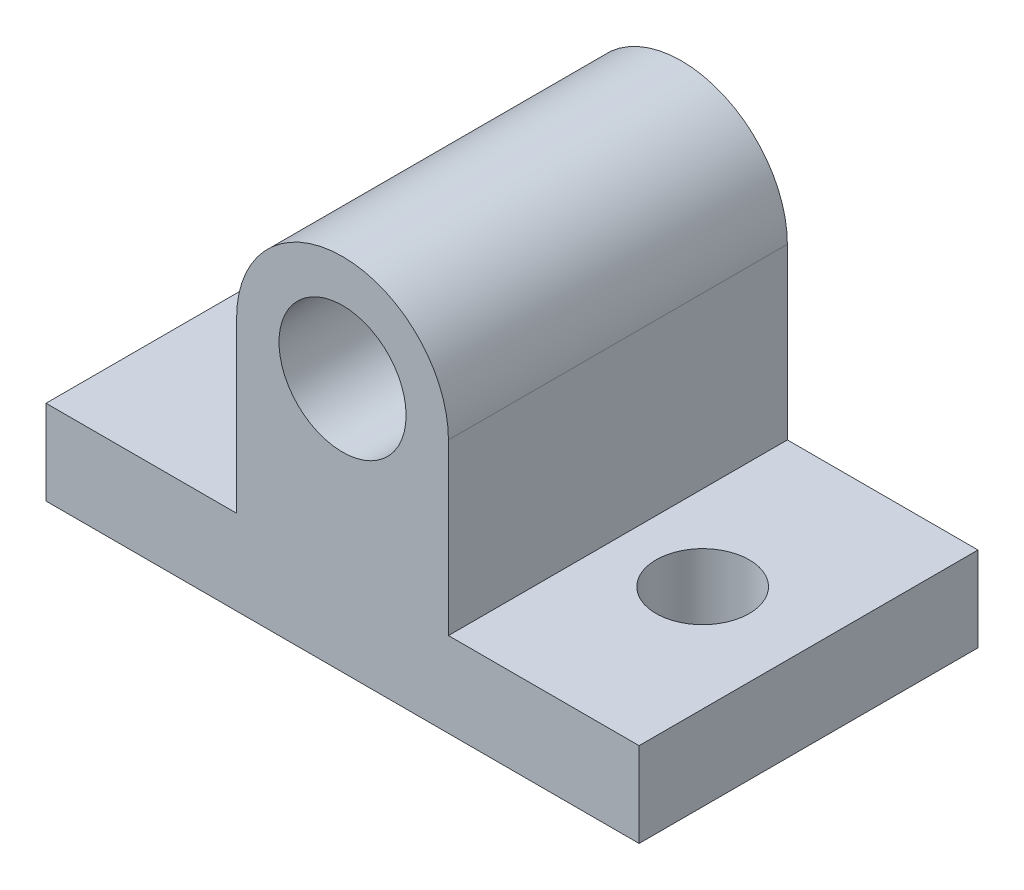
from build123d import *

# Parameters (mm, degrees)
BASE_SKETCH_W                        = 14
BASE_SKETCH_H                        = 8
BASE_EXTRUDE_DEPTH                   = 2
PROTRUSION_EXTRUDE_REACH             = 6
PROTRUSION_SKETCH_W                  = 5
PROTRUSION_SKETCH_H                  = 4
PROTRUSION_EXTRUDE_DIRECTION_2_REACH = 6
F_3_0_3_DIAMETER_HOLE1_D             = 3
F_2_2_2_2_DIAMETER_HOLE1_D           = 2.2
F_3_0_3_DIAMETER_HOLE2_D             = 3
F_3_0_3_DIAMETER_HOLE2_DEPTH         = 6
F_3_0_3_DIAMETER_HOLE2_TIP           = 0.901290929
F_5MM_CUT_SKETCH_R                   = 2.5
F_5_MM_DIAMETER_CUT_DEPTH            = 0.7


with BuildPart() as part:
    # Base Sketch → Base Extrude (new body)
    with BuildSketch(Plane(origin=(0, 0, 0), x_dir=(1, 0, 0), z_dir=(0, 1, 0))):
        Rectangle(BASE_SKETCH_W, BASE_SKETCH_H)
    extrude(amount=BASE_EXTRUDE_DEPTH)

    # Protrusion Extrude: up to this face of the body (flat: up to its plane)
    protrusion_extrude_end = Plane(part.part.faces().sort_by_distance((0, 1, 4))[0])
    # Protrusion Sketch → Protrusion Extrude (add, up to the picked face)
    with BuildSketch(Plane.XY, mode=Mode.PRIVATE) as protrusion_extrude_sk1:
        with BuildLine():
            ThreePointArc((-2.5, 6), (0, 8.5), (2.5, 6))
            Line((2.5, 6), (-2.5, 6))
        make_face()
    protrusion_extrude_tool1 = split(extrude(protrusion_extrude_sk1.sketch, amount=PROTRUSION_EXTRUDE_REACH, mode=Mode.PRIVATE), bisect_by=protrusion_extrude_end, keep=Keep.BOTH, mode=Mode.PRIVATE)
    add(protrusion_extrude_tool1.solids().sort_by_distance((0, 7.061033, 0))[0])
    # Protrusion Sketch → Protrusion Extrude (add, up to the picked face)
    with BuildSketch(Plane.XY, mode=Mode.PRIVATE) as protrusion_extrude_sk2:
        with Locations((0, 4)):
            Rectangle(PROTRUSION_SKETCH_W, PROTRUSION_SKETCH_H)
    protrusion_extrude_tool2 = split(extrude(protrusion_extrude_sk2.sketch, amount=PROTRUSION_EXTRUDE_REACH, mode=Mode.PRIVATE), bisect_by=protrusion_extrude_end, keep=Keep.BOTH, mode=Mode.PRIVATE)
    add(protrusion_extrude_tool2.solids().sort_by_distance((0, 4, 0))[0])

    # Protrusion Extrude direction 2: up to this face of the body (flat: up to its plane)
    protrusion_extrude_direction_2_end = Plane(part.part.faces().sort_by_distance((0, 1, -4))[0])
    # Protrusion Sketch → Protrusion Extrude direction 2 (add, up to the picked face)
    with BuildSketch(Plane.XY, mode=Mode.PRIVATE) as protrusion_extrude_direction_2_sk1:
        with BuildLine():
            ThreePointArc((-2.5, 6), (0, 8.5), (2.5, 6))
            Line((2.5, 6), (-2.5, 6))
        make_face()
    protrusion_extrude_direction_2_tool1 = split(extrude(protrusion_extrude_direction_2_sk1.sketch, amount=-PROTRUSION_EXTRUDE_DIRECTION_2_REACH, mode=Mode.PRIVATE), bisect_by=protrusion_extrude_direction_2_end, keep=Keep.BOTH, mode=Mode.PRIVATE)
    add(protrusion_extrude_direction_2_tool1.solids().sort_by_distance((0, 7.061033, 0))[0])
    # Protrusion Sketch → Protrusion Extrude direction 2 (add, up to the picked face)
    with BuildSketch(Plane.XY, mode=Mode.PRIVATE) as protrusion_extrude_direction_2_sk2:
        with Locations((0, 4)):
            Rectangle(PROTRUSION_SKETCH_W, PROTRUSION_SKETCH_H)
    protrusion_extrude_direction_2_tool2 = split(extrude(protrusion_extrude_direction_2_sk2.sketch, amount=-PROTRUSION_EXTRUDE_DIRECTION_2_REACH, mode=Mode.PRIVATE), bisect_by=protrusion_extrude_direction_2_end, keep=Keep.BOTH, mode=Mode.PRIVATE)
    add(protrusion_extrude_direction_2_tool2.solids().sort_by_distance((0, 4, 0))[0])

    # Ø3.0 (3) Diameter Hole1 (through all)
    with Locations(Plane.XY.offset(4)):
        with Locations((0, 6)):
            Hole(F_3_0_3_DIAMETER_HOLE1_D / 2)

    # Ø2.2 (2.2) Diameter Hole1 (through all)
    with Locations(Plane(origin=(0, 0, 0), x_dir=(-1, 0, 0), z_dir=(0, -1, 0))):
        with Locations((4.5, 0), (-4.5, 0)):
            Hole(F_2_2_2_2_DIAMETER_HOLE1_D / 2)

    # Ø3.0 (3) Diameter Hole2
    with Locations(Plane(origin=(0, 0, 0), x_dir=(-1, 0, 0), z_dir=(0, -1, 0))):
        with Locations((0, 0)):
            Hole(F_3_0_3_DIAMETER_HOLE2_D / 2, depth=F_3_0_3_DIAMETER_HOLE2_DEPTH)
            with Locations((0, 0, -(F_3_0_3_DIAMETER_HOLE2_DEPTH + F_3_0_3_DIAMETER_HOLE2_TIP / 2))):  # 118° drill point
                Cone(0, F_3_0_3_DIAMETER_HOLE2_D / 2, F_3_0_3_DIAMETER_HOLE2_TIP, mode=Mode.SUBTRACT)

    # 5mm Cut Sketch → 5 mm diameter Cut (cut)
    with BuildSketch(Plane(origin=(0, 0, 0), x_dir=(1, 0, 0), z_dir=(0, 1, 0))):
        Circle(F_5MM_CUT_SKETCH_R)
    extrude(amount=F_5_MM_DIAMETER_CUT_DEPTH, mode=Mode.SUBTRACT)


solid = part.part
